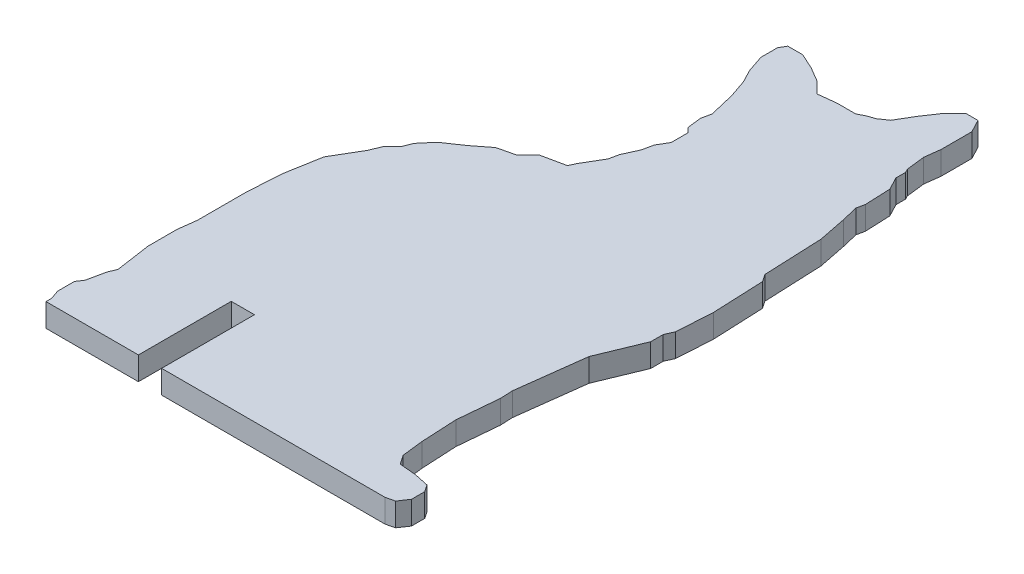
from build123d import *

# Parameters (mm, degrees)
BOSS_EXTRUDE1_DEPTH = 2.5
SKETCH2_W           = 2.5
SKETCH2_H           = 2.5
CUT_EXTRUDE1_DEPTH  = 10


with BuildPart() as part:
    # Sketch1 → Boss-Extrude1 (new body)
    with BuildSketch(Plane(origin=(0, 0, 0), x_dir=(1, 0, 0), z_dir=(0, 1, 0))):
        Polygon((19.021261999, 44.804158017), (19.332438403, 45.488746105), (20.577144018, 47.604745652), (20.794967501, 48.631627785), (21.527084588, 50.242285376), (21.770981653, 51.392085822), (22.447946599, 52.542926231), (22.447946599, 54.357273616), (21.948192274, 54.857027941), (21.770981653, 56.379920241), (21.990995409, 57.417127949), (21.770981653, 58.340331586), (21.340284184, 60.1475889), (20.68605576, 62.074448432), (19.954791211, 63.47474225), (19.332438403, 65.307720452), (19.332438403, 67.115506175), (19.741207407, 67.810413481), (21.340284184, 67.810413481), (22.992716517, 67.059307875), (24.51836959, 66.161864891), (25.760939094, 64.919295387), (27.687055742, 65.143427014), (29.724933341, 65.143427014), (30.485439327, 65.540580139), (31.279820672, 65.810297182), (32.201793055, 66.437748451), (33.254785535, 68.227835667), (34.276233434, 69.742789054), (35.243443216, 70.709998836), (35.656263686, 71.122819306), (36.913233915, 71.122819306), (37.63391638, 69.742789054), (37.63391638, 66.437748451), (37.423054008, 64.767648146), (37.654974628, 62.774595341), (37.855798717, 62.390038575), (37.855798717, 61.339547521), (38.570896495, 59.97021135), (38.688814239, 57.225826771), (38.50937952, 56.379920241), (38.931857999, 54.607150778), (39.532654393, 51.600225744), (39.660205894, 48.631627785), (39.804568301, 45.271777514), (40.33944819, 44.485828851), (40.577016369, 38.956733507), (40.33944819, 35.114073385), (39.92710204, 34.206911855), (39.92710204, 32.859942326), (37.98561411, 28.148501466), (37.060494228, 20.821243477), (37.11895116, 19.460733181), (36.71985388, 15.068979081), (36.91940252, 11.218958378), (37.185464562, 8.932504932), (37.855798717, 7.947520745), (39.660205894, 7.783546628), (41.232731094, 7.449980677), (41.741559995, 6.702311148), (41.741559995, 5.276917294), (41.050907419, 4.252580704), (40.133275115, 4.033894683), (3.616707841, 4.033894683), (3.616707841, 4.626457176), (3.269950211, 5.647741518), (3.269950211, 6.261397474), (3.269950211, 7.449980677), (3.734735993, 8.139324495), (4.145489026, 10.075731655), (4.493765097, 10.920898955), (3.940112509, 14.699799013), (3.940112509, 17.811459581), (4.189387556, 19.785801077), (4.189387556, 24.971460981), (4.417715683, 28.664663454), (5.09342811, 32.508342262), (6.832899379, 35.465443418), (7.307908954, 36.618157008), (8.257829647, 37.568077701), (8.694357753, 38.627407672), (9.840028976, 39.979843625), (11.786481729, 41.304508301), (13.461509637, 42.616844106), (15.348517574, 43.066547386), (16.554775804, 44.272805615), align=None)
    extrude(amount=BOSS_EXTRUDE1_DEPTH)

    # Sketch2 → Cut-Extrude1 (cut)
    with BuildSketch(Plane.XY.offset(-4.033894683)):
        with Locations((14.819950211, 1.25)):
            Rectangle(SKETCH2_W, SKETCH2_H)
    extrude(amount=-CUT_EXTRUDE1_DEPTH, mode=Mode.SUBTRACT)


solid = part.part
